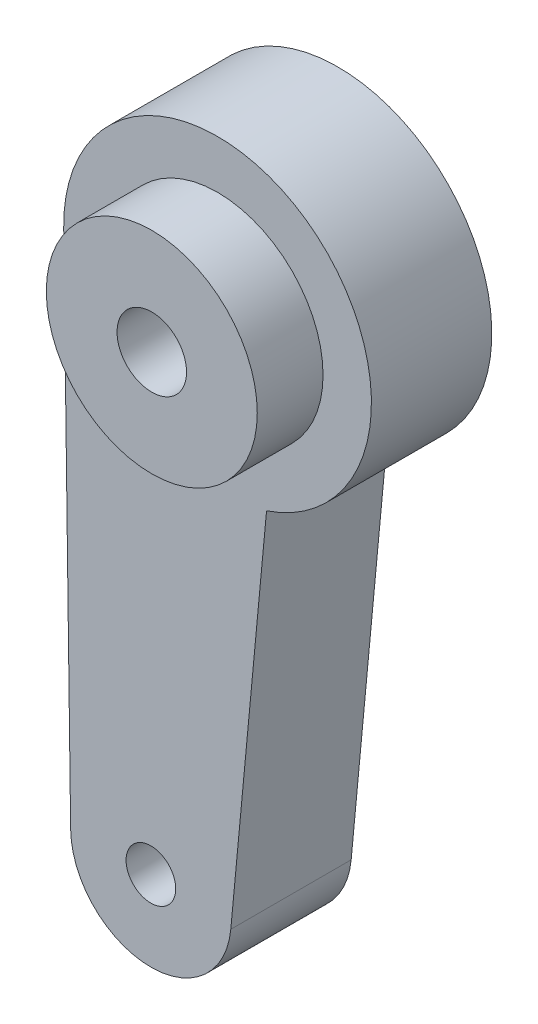
from build123d import *

# Parameters (mm, degrees)
ESBO_O1_R                = 5.5
ESBO_O1_R_2              = 2
RESSALTO_EXTRUS_O1_DEPTH = 9.7
ESBO_O2_R                = 8.5
ESBO_O2_R_2              = 2.8
RESSALTO_EXTRUS_O2_DEPTH = 5.3


with BuildPart() as part:
    # Esboço1 → Ressalto-extrusão1 (new body)
    with BuildSketch(Plane.XY):
        with BuildLine():
            Line((-12.397968723, -0.166390596), (-11.838135129, -41.880282782))
            ThreePointArc((-11.838135129, -41.880282782), (-5.631724082, -48.255001448), (1.066308546, -42.398984451))
            Line((1.066308546, -42.398984451), (3.948309434, -11.753644835))
            ThreePointArc((3.948309434, -11.753644835), (7.17044634, 10.115434423), (-12.397968723, -0.166390596))
        make_face()
        Circle(ESBO_O1_R, mode=Mode.SUBTRACT)
        with Locations((-5.372000333, -41.793502112)):
            Circle(ESBO_O1_R_2, mode=Mode.SUBTRACT)
    extrude(amount=RESSALTO_EXTRUS_O1_DEPTH)

    # Esboço2 → Ressalto-extrusão2 (add)
    with BuildSketch(Plane.XY.offset(9.7)):
        Circle(ESBO_O2_R)
        Circle(ESBO_O2_R_2, mode=Mode.SUBTRACT)
    extrude(amount=RESSALTO_EXTRUS_O2_DEPTH)


solid = part.part
